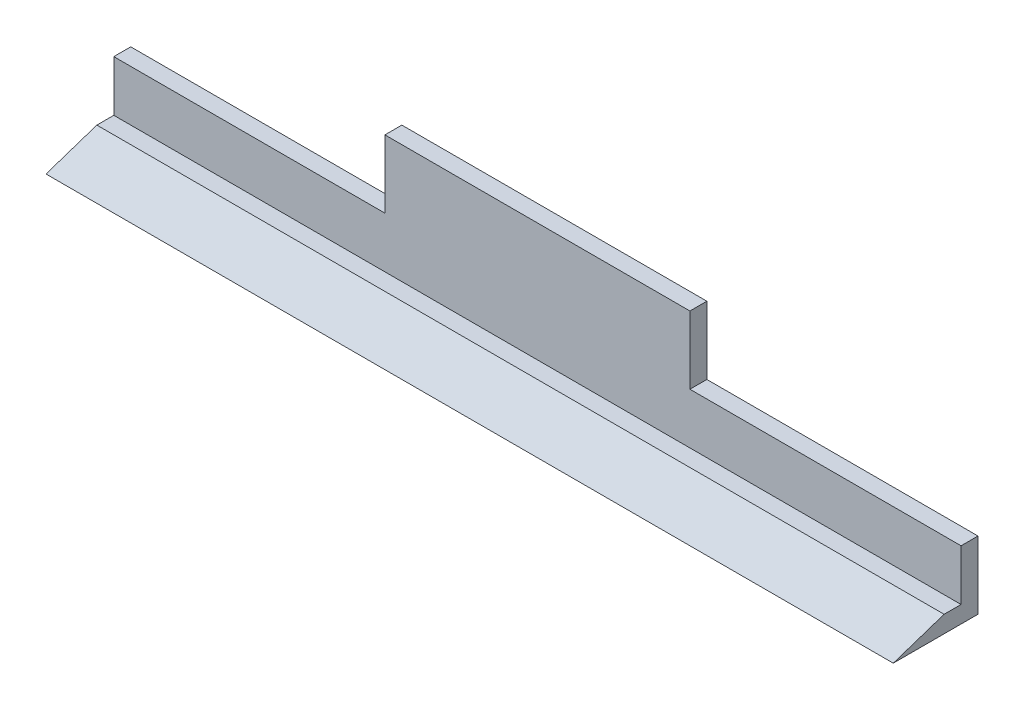
from build123d import *

# Parameters (mm, degrees)
ESQUISSE1_W        = 90
ESQUISSE1_H        = 20
ESQUISSE1_W_2      = 250
BOSS_EXTRU_1_DEPTH = 5
BOSS_EXTRU_2_DEPTH = 250


with BuildPart() as part:
    # Esquisse1 → Boss.-Extru.1 (new body)
    with BuildSketch(Plane.XY):
        with Locations((-125, 30)):
            Rectangle(ESQUISSE1_W, ESQUISSE1_H)
        with Locations((-125, 10)):
            Rectangle(ESQUISSE1_W_2, ESQUISSE1_H)
    extrude(amount=BOSS_EXTRU_1_DEPTH)

    # Esquisse2 → Boss.-Extru.2 (add)
    with BuildSketch(Plane(origin=(0, 0, 0), x_dir=(0, 0, -1), z_dir=(1, 0, 0))):
        Polygon((-25, 0), (-5, 0), (-5, 5), (-10, 5), align=None)
    extrude(amount=-BOSS_EXTRU_2_DEPTH)


solid = part.part
